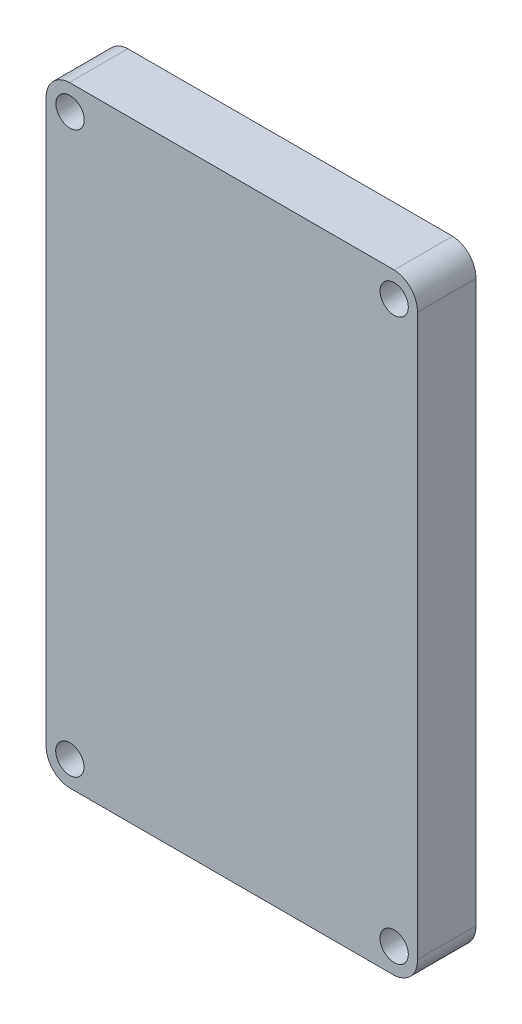
from build123d import *

# Parameters (mm, degrees)
SKETCH_1_R      = 1.55
EXTRUDE_1_DEPTH = 6.4


with BuildPart() as part:
    # 草图1 → 凸台-拉伸1 (new body)
    with BuildSketch(Plane.XY):
        with BuildLine():
            Line((0, 2.75), (0, 64.13))
            ThreePointArc((0, 64.13), (-0.700235603, 66.031255116), (-2.54, 66.88))
            Line((-2.54, 66.88), (-38.1, 66.88))
            ThreePointArc((-38.1, 66.88), (-39.939764397, 66.031255116), (-40.64, 64.13))
            Line((-40.64, 64.13), (-40.64, 2.75))
            ThreePointArc((-40.64, 2.75), (-39.939764397, 0.848744884), (-38.1, 0))
            Line((-38.1, 0), (-2.54, 0))
            ThreePointArc((-2.54, 0), (-0.700235603, 0.848744884), (0, 2.75))
        make_face()
        with Locations((-2.54, 2.75)):
            Circle(SKETCH_1_R, mode=Mode.SUBTRACT)
        with Locations((-2.54, 64.13)):
            Circle(SKETCH_1_R, mode=Mode.SUBTRACT)
        with Locations((-38.049, 2.75)):
            Circle(SKETCH_1_R, mode=Mode.SUBTRACT)
        with Locations((-38.024, 64.13)):
            Circle(SKETCH_1_R, mode=Mode.SUBTRACT)
    extrude(amount=EXTRUDE_1_DEPTH)


solid = part.part
